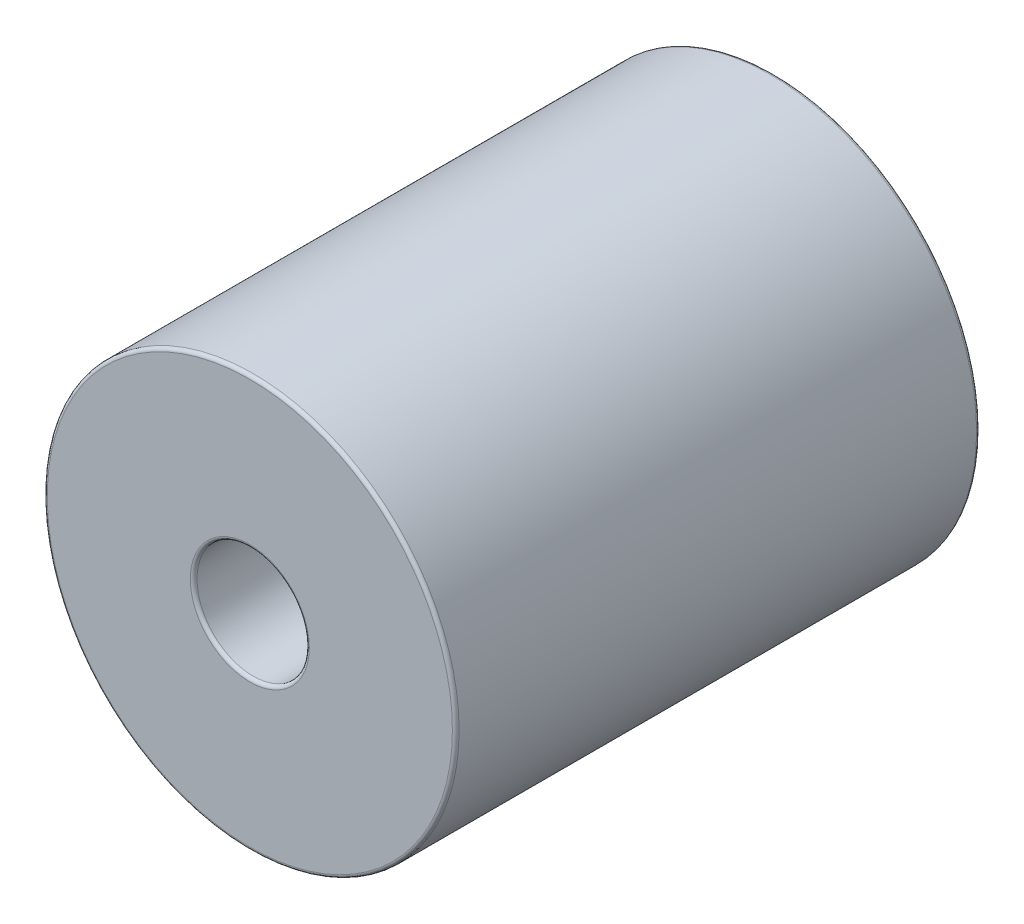
from build123d import *

# Parameters (mm, degrees)
SKETCH3_R                = 2.1828125
SKETCH3_R_2              = 0.5953125
BOSS_EXTRUDE1_DEPTH      = 2.778125
BOSS_EXTRUDE1_DEPTH_BACK = 2.778125
FILLET1_R                = 0.03571875


with BuildPart() as part:
    # Sketch3 → Boss-Extrude1 (new body, two sides)
    with BuildSketch(Plane.XY) as boss_extrude1_sk:
        Circle(SKETCH3_R)
        Circle(SKETCH3_R_2, mode=Mode.SUBTRACT)
    extrude(amount=BOSS_EXTRUDE1_DEPTH)
    extrude(boss_extrude1_sk.sketch, amount=-BOSS_EXTRUDE1_DEPTH_BACK)

    # Fillet1
    fillet1_edges = [part.edges().sort_by_distance(p)[0] for p in [
        (-2.1828125, 0, 2.778125),
        (-0.5953125, 0, 2.778125),
        (-2.1828125, 0, -2.778125),
        (-0.5953125, 0, -2.778125),
    ]]
    fillet(fillet1_edges, radius=FILLET1_R)


solid = part.part
